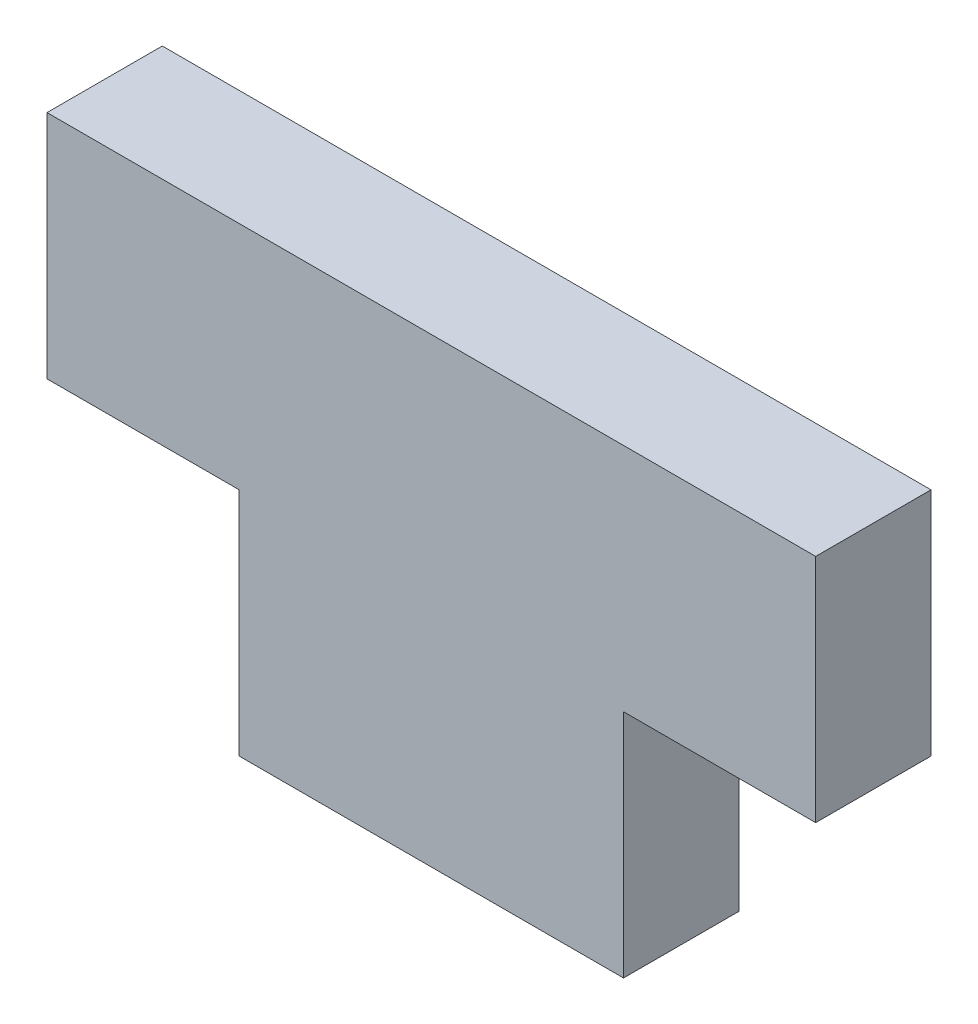
from build123d import *

# Parameters (mm, degrees)
PLAT_W                      = 60
PLAT_H                      = 15
EL_MENT_M_CANO_SOUD_1_DEPTH = 100
ESQUISSE2_W                 = 25
ESQUISSE2_H                 = 30
ENL_V_MAT_EXTRU_1_DEPTH     = 20


with BuildPart() as part:
    # plat → Elément mécano-soudé1 (new body)
    with BuildSketch(Plane.YZ.offset(-50)):
        Rectangle(PLAT_W, PLAT_H)
    extrude(amount=EL_MENT_M_CANO_SOUD_1_DEPTH)

    # Esquisse2 → Enlèv. mat.-Extru.1 (cut)
    with BuildSketch(Plane.XY.offset(7.5)):
        with Locations((-37.5, -15)):
            Rectangle(ESQUISSE2_W, ESQUISSE2_H)
        with Locations((37.5, -15)):
            Rectangle(ESQUISSE2_W, ESQUISSE2_H)
    extrude(amount=-ENL_V_MAT_EXTRU_1_DEPTH, mode=Mode.SUBTRACT)


solid = part.part
